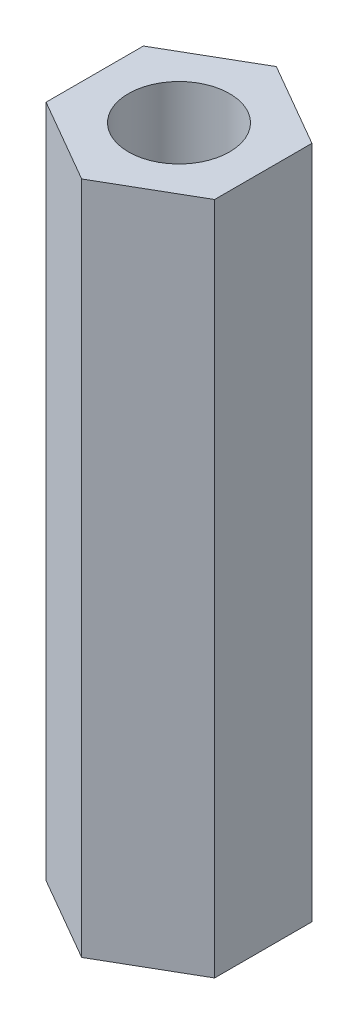
from build123d import *

# Parameters (mm, degrees)
BOSS_EXTRUDE1_DEPTH = 40
SKETCH3_R           = 3
CUT_EXTRUDE1_DEPTH  = 12
SKETCH4_R           = 3
CUT_EXTRUDE2_DEPTH  = 12


with BuildPart() as part:
    # Sketch1 → Boss-Extrude1 (new body)
    with BuildSketch(Plane(origin=(0, 0, 0), x_dir=(1, 0, 0), z_dir=(0, 1, 0))):
        Polygon((0, -5.773502692), (5, -2.886751346), (5, 2.886751346), (0, 5.773502692), (-5, 2.886751346), (-5, -2.886751346), align=None)
    extrude(amount=BOSS_EXTRUDE1_DEPTH)

    # Sketch3 → Cut-Extrude1 (cut)
    with BuildSketch(Plane.XZ):
        Circle(SKETCH3_R)
    extrude(amount=-CUT_EXTRUDE1_DEPTH, mode=Mode.SUBTRACT)

    # Sketch4 → Cut-Extrude2 (cut)
    with BuildSketch(Plane(origin=(0, 40, 0), x_dir=(1, 0, 0), z_dir=(0, 1, 0))):
        Circle(SKETCH4_R)
    extrude(amount=-CUT_EXTRUDE2_DEPTH, mode=Mode.SUBTRACT)


solid = part.part
